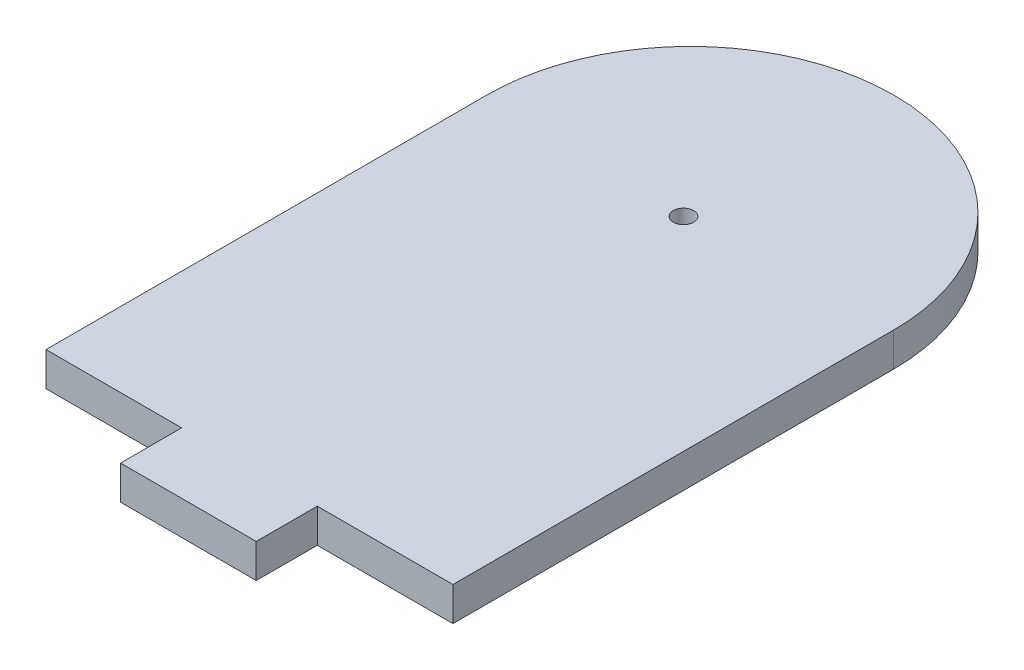
from build123d import *

# Parameters (mm, degrees)
SKETCH1_W           = 60
SKETCH1_H           = 65
SKETCH1_W_2         = 20
SKETCH1_H_2         = 9
BOSS_EXTRUDE1_DEPTH = 5
SKETCH2_R           = 1.5
CUT_EXTRUDE1_DEPTH  = 6


with BuildPart() as part:
    # Sketch1 → Boss-Extrude1 (new body)
    with BuildSketch(Plane(origin=(0, 0, 0), x_dir=(1, 0, 0), z_dir=(0, 1, 0))):
        Rectangle(SKETCH1_W, SKETCH1_H)
        with Locations((0, -37)):
            Rectangle(SKETCH1_W_2, SKETCH1_H_2)
        with BuildLine():
            Line((-30, 32.5), (30, 32.5))
            ThreePointArc((30, 32.5), (0, 62.5), (-30, 32.5))
        make_face()
    extrude(amount=BOSS_EXTRUDE1_DEPTH)

    # Sketch2 → Cut-Extrude1 (cut, through all)
    with BuildSketch(Plane(origin=(0, 5, 0), x_dir=(1, 0, 0), z_dir=(0, 1, 0))):
        with Locations((0, 31.5)):
            Circle(SKETCH2_R)
    extrude(amount=-CUT_EXTRUDE1_DEPTH, mode=Mode.SUBTRACT)


solid = part.part
